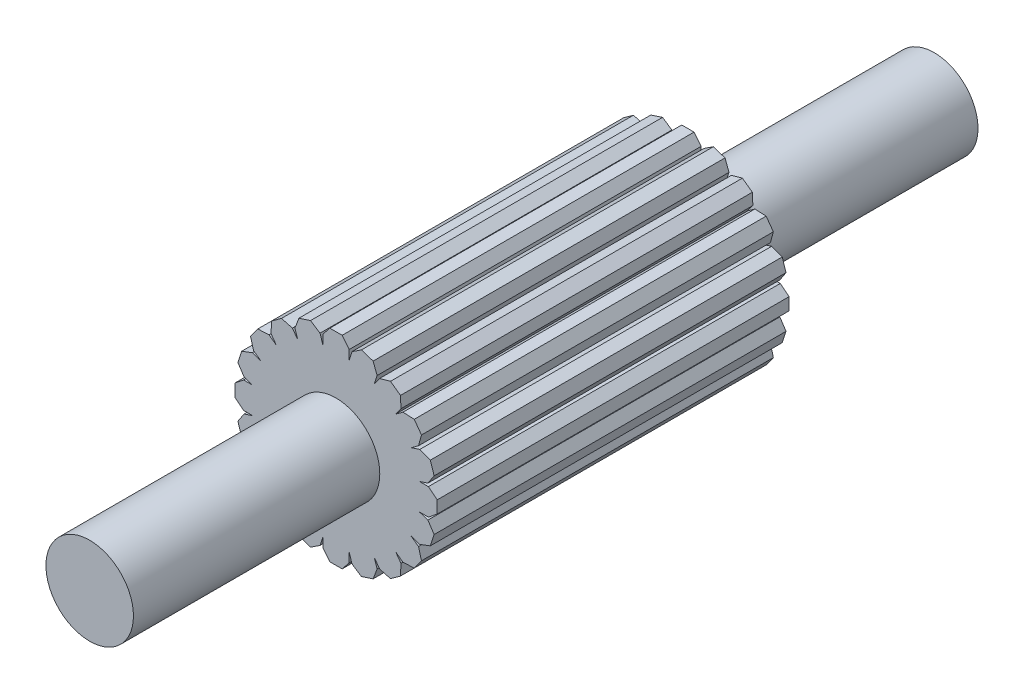
from build123d import *

# Parameters (mm, degrees)
SKETCH1_R           = 24.875
BOSS_EXTRUDE1_DEPTH = 480
SKETCH4_R           = 47.5
BOSS_EXTRUDE2_DEPTH = 100
BOSS_EXTRUDE3_DEPTH = 200
CIRPATTERN1_COUNT   = 20


with BuildPart() as part:
    # Sketch1 → Boss-Extrude1 (new body)
    with BuildSketch(Plane.XY):
        Circle(SKETCH1_R)
    extrude(amount=BOSS_EXTRUDE1_DEPTH)

    # Sketch4 → Boss-Extrude2 (add, symmetric)
    with BuildSketch(Plane.XY.offset(240)):
        Circle(SKETCH4_R)
    extrude(amount=BOSS_EXTRUDE2_DEPTH, both=True)

    # Sketch5 → Boss-Extrude3 (add)
    with BuildSketch(Plane.XY.offset(340)):
        with BuildLine():
            ThreePointArc((7.5, 46.904157598), (0, 47.5), (-7.5, 46.904157598))
            Line((-7.5, 46.904157598), (-7.5, 37.5))
            Line((-7.5, 37.5), (7.5, 37.5))
            Line((7.5, 37.5), (7.5, 46.904157598))
        make_face()
        with BuildLine():
            Line((-7.5, 37.5), (-7.5, 46.904157598))
            ThreePointArc((-7.5, 46.904157598), (-30.822070015, -36.142080737), (47.5, 0))
            ThreePointArc((47.5, 0), (36.142080737, 30.822070015), (7.5, 46.904157598))
            Line((7.5, 46.904157598), (7.5, 37.5))
            Line((7.5, 37.5), (-7.5, 37.5))
        make_face()
        with BuildLine():
            Line((-3.5, 57.5), (-7.5, 52.5))
            Line((-7.5, 52.5), (-7.5, 46.904157598))
            ThreePointArc((-7.5, 46.904157598), (0, 47.5), (7.5, 46.904157598))
            Line((7.5, 46.904157598), (7.5, 52.5))
            Line((7.5, 52.5), (3.5, 57.5))
            Line((3.5, 57.5), (-3.5, 57.5))
        make_face()
    boss_extrude3 = extrude(amount=-BOSS_EXTRUDE3_DEPTH)

    # CirPattern1: Boss-Extrude3 ×20 about axis
    cirpattern1_axis = Axis((0, 0, 0), (0, 0, 1))
    for i in range(1, CIRPATTERN1_COUNT):
        add(boss_extrude3.rotate(cirpattern1_axis, i * 360 / CIRPATTERN1_COUNT))


solid = part.part
